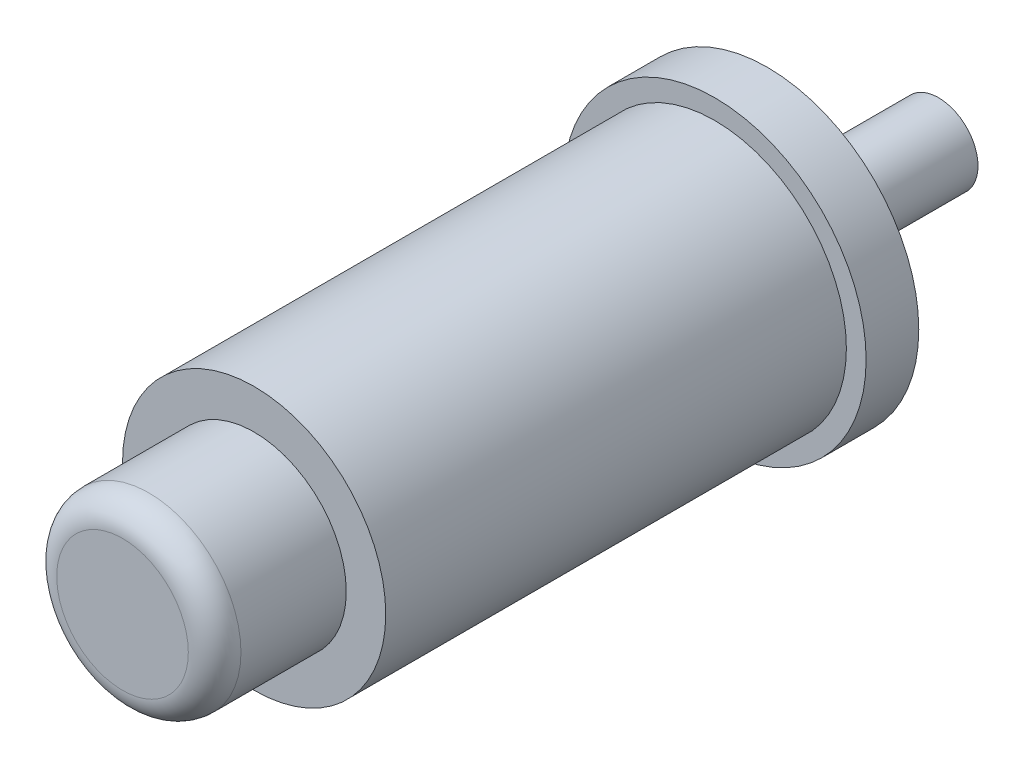
from build123d import *

# Parameters (mm, degrees)
SKETCH_1_R      = 1
SKETCH_1_R_2    = 0.3
EXTRUDE_1_DEPTH = 3.9
SKETCH_1_3_R    = 1.15
SKETCH_1_3_R_2  = 1
EXTRUDE_2_DEPTH = 0.4
SKETCH_1_4_R    = 0.3
EXTRUDE_3_DEPTH = 1.3
SKETCH_2_R      = 0.7
EXTRUDE_4_DEPTH = 1
FILLET_1_R      = 0.2


with BuildPart() as part:
    # Sketch 1 → Extrude 1 (new body)
    with BuildSketch(Plane.XY):
        Circle(SKETCH_1_R)
        Circle(SKETCH_1_R_2, mode=Mode.SUBTRACT)
        Circle(SKETCH_1_R_2)
    extrude(amount=EXTRUDE_1_DEPTH)

    # Sketch 1_3 → Extrude 2 (add)
    with BuildSketch(Plane.XY):
        Circle(SKETCH_1_3_R)
        Circle(SKETCH_1_3_R_2, mode=Mode.SUBTRACT)
    extrude(amount=EXTRUDE_2_DEPTH)

    # Sketch 2 → Extrude 4 (add)
    with BuildSketch(Plane.XY.offset(3.9)):
        Circle(SKETCH_2_R)
    extrude(amount=EXTRUDE_4_DEPTH)

    # Fillet 1
    fillet_1_edges = [part.edges().sort_by_distance(p)[0] for p in [
        (-0.7, 0, 4.9),
    ]]
    fillet(fillet_1_edges, radius=FILLET_1_R)


with BuildPart() as body_2:
    # Sketch 1_4 → Extrude 3 (new body)
    with BuildSketch(Plane.XY):
        Circle(SKETCH_1_4_R)
    extrude(amount=-EXTRUDE_3_DEPTH)


solid = Compound([part.part, body_2.part])
